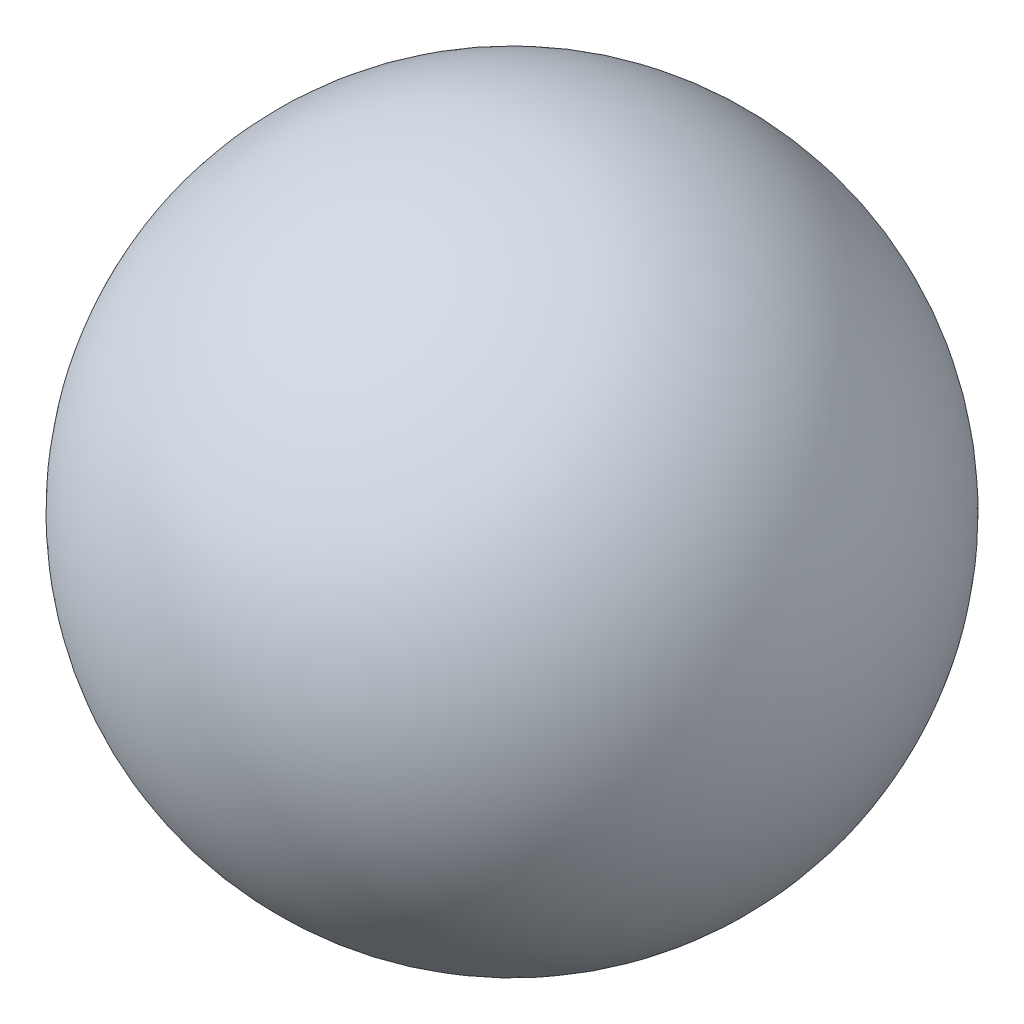
from build123d import *


with BuildPart() as part:
    # Sketch1 → Revolve1 (revolve)
    with BuildSketch(Plane(origin=(0, 0, 0), x_dir=(1, 0, 0), z_dir=(0, 1, 0))):
        with BuildLine():
            Line((-15, 0), (15, 0))
            ThreePointArc((15, 0), (0, 15), (-15, 0))
        make_face()
    revolve(axis=Axis((-15, 0, 0), (1, 0, 0)))


solid = part.part
